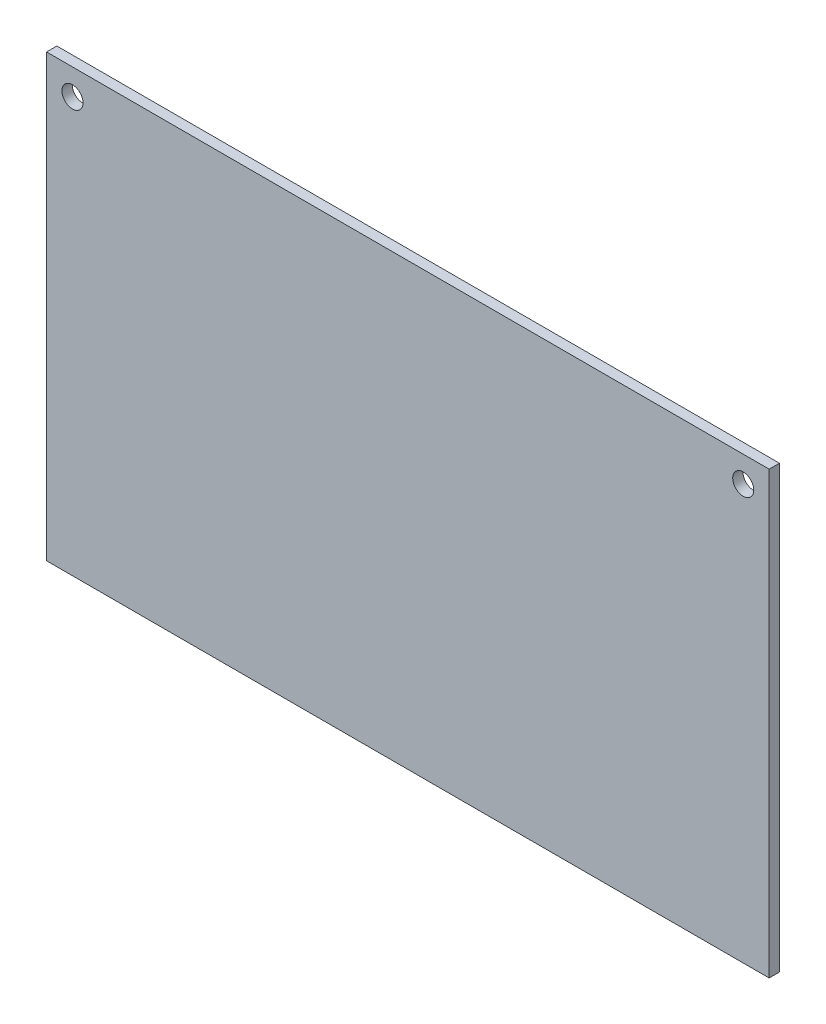
from build123d import *

# Parameters (mm, degrees)
SKETCH1_W           = 111.5
SKETCH1_H           = 68
SKETCH1_R           = 1.6256
BOSS_EXTRUDE1_DEPTH = 1.5875


with BuildPart() as part:
    # Sketch1 → Boss-Extrude1 (new body)
    with BuildSketch(Plane.XY):
        with Locations((55.75, 34)):
            Rectangle(SKETCH1_W, SKETCH1_H)
        with Locations((4, 64)):
            Circle(SKETCH1_R, mode=Mode.SUBTRACT)
        with Locations((107.5, 64)):
            Circle(SKETCH1_R, mode=Mode.SUBTRACT)
    extrude(amount=BOSS_EXTRUDE1_DEPTH)


solid = part.part
